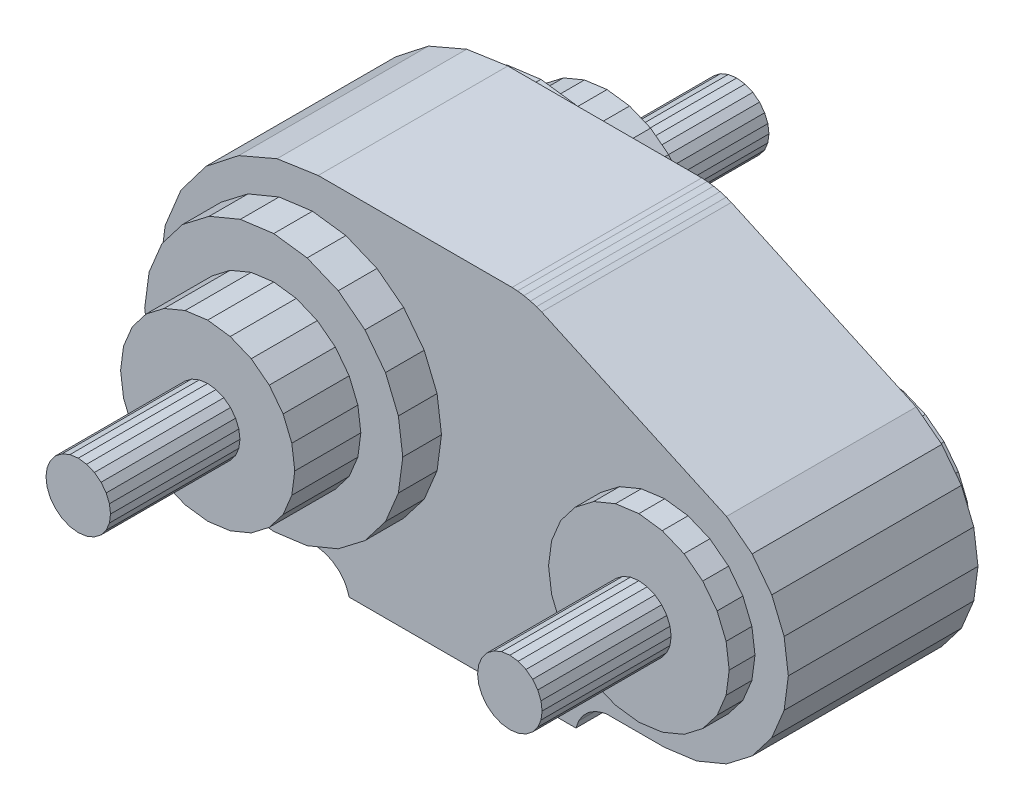
from build123d import *

# Parameters (mm, degrees)
BOSS_EXTRUDE1_DEPTH  = 14.699999809
BOSS_EXTRUDE2_DEPTH  = 2.000000954
BOSS_EXTRUDE3_DEPTH  = 10
BOSS_EXTRUDE4_DEPTH  = 3.000000954
BOSS_EXTRUDE5_DEPTH  = 5.119998932
BOSS_EXTRUDE6_DEPTH  = 10.029998779
BOSS_EXTRUDE7_DEPTH  = 2
BOSS_EXTRUDE8_DEPTH  = 3
BOSS_EXTRUDE9_DEPTH  = 5.130000114
BOSS_EXTRUDE10_DEPTH = 10.050000191
CUT_EXTRUDE1_DEPTH   = 6
CUT_EXTRUDE2_DEPTH   = 6
DRAFT1_ANGLE         = 19.74294867
CHAMFER1_SIZE2       = 0.158303092
CHAMFER1_SIZE        = 0.157016973
CHAMFER2_SIZE2       = 0.157642231
CHAMFER2_SIZE        = 0.157642267


with BuildPart() as part:
    # Sketch1 → Boss-Extrude1 (new body)
    with BuildSketch(Plane.XY.offset(14.699999809)):
        Polygon((26.931087494, 2.467746735), (29.242494583, 3.427928209), (31.226976395, 4.953178406), (32.749523163, 6.939733505), (33.706558228, 9.252446175), (34.032974243, 11.733979225), (33.706558228, 14.215512276), (32.749523163, 16.528224945), (31.226976395, 18.514780045), (29.242494583, 20.040029526), (14.914542198, 26.600000381), (14.518286705, 26.754508972), (14.043248177, 26.893892288), (13.535926819, 27.004508972), (13.045982361, 27.075529099), (12.62137413, 27.100000381), (-2.402890205, 27.100000381), (-5.592948914, 26.629587173), (-8.556154251, 25.357906342), (-11.094871521, 23.369771957), (-13.039776802, 20.797786713), (-14.26115036, 17.813493729), (-14.677532196, 14.615934372), (-14.26115036, 11.418374062), (-13.039776802, 8.434081078), (-11.094871521, 5.862095833), (-8.556154251, 3.873961449), (-5.592948914, 2.602279902), (-2.402890205, 2.131867886), (-1.797713399, 1.993236542), (-1.238033295, 1.724506974), (-0.751430988, 1.338922024), (0, 0.406370154), (0, 0), (17.573465347, 0), (17.573465347, 0.255007923), (18.116666794, 1.108045936), (18.5574646, 1.545258999), (19.08385849, 1.874450445), (19.819337772, 2.131654199), (24.450000763, 2.137956142), align=None)
    extrude(amount=-BOSS_EXTRUDE1_DEPTH)

    # Sketch2 → Boss-Extrude2 (add)
    with BuildSketch(Plane.XY.offset(14.699999809)):
        Polygon((17.450000763, 11.829999924), (17.688518524, 13.64173317), (18.387823105, 15.329999924), (19.50025177, 16.779747009), (20.950000763, 17.892177582), (22.638267517, 18.591480255), (24.450000763, 18.829999924), (26.261734009, 18.591480255), (27.950000763, 17.892177582), (29.399747849, 16.779747009), (30.512178421, 15.329999924), (31.211481094, 13.64173317), (31.450000763, 11.829999924), (31.211481094, 10.018266678), (30.512178421, 8.329999924), (29.399747849, 6.880252361), (27.950000763, 5.767822266), (26.261734009, 5.068519115), (24.450000763, 4.829999924), (22.638267517, 5.068519115), (20.950000763, 5.767822266), (19.50025177, 6.880252361), (18.387823105, 8.329999924), (17.688518524, 10.018266678), align=None)
    extrude(amount=BOSS_EXTRUDE2_DEPTH)

    # Sketch3 → Boss-Extrude3 (add)
    with BuildSketch(Plane.XY.offset(16.700000763)):
        Polygon((21.950000763, 11.829999924), (22.03518486, 12.47704792), (22.284936905, 13.079999924), (22.68223381, 13.597766876), (23.200000763, 13.995063782), (23.802951813, 14.244814873), (24.450000763, 14.329999924), (25.097047806, 14.244814873), (25.700000763, 13.995063782), (26.217767715, 13.597766876), (26.615062714, 13.079999924), (26.864814758, 12.47704792), (26.950000763, 11.829999924), (26.864814758, 11.182951927), (26.615062714, 10.579999924), (26.217767715, 10.062232971), (25.700000763, 9.664936066), (25.097047806, 9.415184975), (24.450000763, 9.329999924), (23.802951813, 9.415184975), (23.200000763, 9.664936066), (22.68223381, 10.062232971), (22.284936905, 10.579999924), (22.03518486, 11.182951927), align=None)
    extrude(amount=BOSS_EXTRUDE3_DEPTH)

    # Sketch4 → Boss-Extrude4 (add)
    with BuildSketch(Plane.XY.offset(14.699999809)):
        Polygon((-0.259341866, 4.820741653), (-2.847532272, 4.480000019), (-5.435722828, 4.820741653), (-7.847532272, 5.819746017), (-9.918600082, 7.408932209), (-11.507786751, 9.479999542), (-12.506790161, 11.891809464), (-12.847532272, 14.479999542), (-12.506790161, 17.068189621), (-11.507786751, 19.479999542), (-9.918600082, 21.551067352), (-7.847532272, 23.140254974), (-5.435722828, 24.139257431), (-2.847532272, 24.479999542), (-0.259341866, 24.139257431), (2.152467728, 23.140254974), (4.223535538, 21.551067352), (5.812721729, 19.479999542), (6.811726093, 17.068189621), (7.152467728, 14.479999542), (6.811726093, 11.891809464), (5.812721729, 9.479999542), (4.223535538, 7.408932209), (2.152467728, 5.819746017), align=None)
    extrude(amount=BOSS_EXTRUDE4_DEPTH)

    # Sketch5 → Boss-Extrude5 (add)
    with BuildSketch(Plane.XY.offset(17.700000763)):
        Polygon((-1.100503802, 7.960000515), (-2.847532272, 7.730000019), (-4.594560623, 7.960000515), (-6.222532272, 8.634328842), (-7.620502949, 9.707029343), (-8.693203926, 11.104999542), (-9.367531776, 12.732971191), (-9.597532272, 14.479999542), (-9.367531776, 16.227027893), (-8.693203926, 17.854999542), (-7.620502949, 19.252971649), (-6.222532272, 20.32567215), (-4.594560623, 21), (-2.847532272, 21.229999542), (-1.100503802, 21), (0.527467668, 20.32567215), (1.925438523, 19.252971649), (2.998139143, 17.854999542), (3.672466993, 16.227027893), (3.902467728, 14.479999542), (3.672466993, 12.732971191), (2.998139143, 11.104999542), (1.925438523, 9.707029343), (0.527467668, 8.634328842), align=None)
    extrude(amount=BOSS_EXTRUDE5_DEPTH)

    # Sketch6 → Boss-Extrude6 (add)
    with BuildSketch(Plane.XY.offset(22.819999695)):
        Polygon((-1.597532272, 12.314936638), (-2.200484753, 12.065185547), (-2.847532272, 11.979999542), (-3.49458003, 12.065185547), (-4.097532272, 12.314936638), (-4.615299225, 12.71223259), (-5.012595654, 13.229999542), (-5.262346745, 13.832952499), (-5.347532272, 14.479999542), (-5.262346745, 15.127047539), (-5.012595654, 15.729999542), (-4.615299225, 16.247766495), (-4.097532272, 16.6450634), (-3.49458003, 16.894815445), (-2.847532272, 16.979999542), (-2.200484753, 16.894815445), (-1.597532272, 16.6450634), (-1.07976532, 16.247766495), (-0.682468772, 15.729999542), (-0.432717741, 15.127047539), (-0.347532302, 14.479999542), (-0.432717741, 13.832952499), (-0.682468772, 13.229999542), (-1.07976532, 12.71223259), align=None)
    extrude(amount=BOSS_EXTRUDE6_DEPTH)

    # Sketch7 → Boss-Extrude7 (add)
    with BuildSketch(Plane(origin=(0, 0, 0), x_dir=(-1, 0, 0), z_dir=(0, 0, -1))):
        Polygon((-27.950000763, 5.767822266), (-29.399747849, 6.880252361), (-30.512178421, 8.329999924), (-31.211481094, 10.018266678), (-31.450000763, 11.829999924), (-31.211481094, 13.64173317), (-30.512178421, 15.329999924), (-29.399747849, 16.779747009), (-27.950000763, 17.892177582), (-26.261734009, 18.591480255), (-24.450000763, 18.829999924), (-22.638267517, 18.591480255), (-20.950000763, 17.892177582), (-19.50025177, 16.779747009), (-18.387823105, 15.329999924), (-17.688518524, 13.64173317), (-17.450000763, 11.829999924), (-17.688518524, 10.018266678), (-18.387823105, 8.329999924), (-19.50025177, 6.880252361), (-20.950000763, 5.767822266), (-22.638267517, 5.068519115), (-24.450000763, 4.829999924), (-26.261734009, 5.068519115), align=None)
    extrude(amount=BOSS_EXTRUDE7_DEPTH)

    # Sketch8 → Boss-Extrude8 (add)
    with BuildSketch(Plane(origin=(0, 0, 0), x_dir=(-1, 0, 0), z_dir=(0, 0, -1))):
        Polygon((9.918600082, 21.551067352), (11.507786751, 19.479999542), (12.506790161, 17.068189621), (12.847532272, 14.479999542), (12.506790161, 11.891809464), (11.507786751, 9.479999542), (9.918600082, 7.408932209), (7.847532272, 5.819746017), (5.435722828, 4.820741653), (2.847532272, 4.480000019), (0.259341866, 4.820741653), (-2.152467728, 5.819746017), (-4.223535538, 7.408932209), (-5.812721729, 9.479999542), (-6.811726093, 11.891809464), (-7.152467728, 14.479999542), (-6.811726093, 17.068189621), (-5.812721729, 19.479999542), (-4.223535538, 21.551067352), (-2.152467728, 23.140254974), (0.259341866, 24.139257431), (2.847532272, 24.479999542), (5.435722828, 24.139257431), (7.847532272, 23.140254974), align=None)
    extrude(amount=BOSS_EXTRUDE8_DEPTH)

    # Sketch9 → Boss-Extrude9 (add)
    with BuildSketch(Plane(origin=(0, 0, -3), x_dir=(-1, 0, 0), z_dir=(0, 0, -1))):
        Polygon((4.594560623, 21), (6.222532272, 20.32567215), (7.620502949, 19.252971649), (8.693203926, 17.854999542), (9.367531776, 16.227027893), (9.597532272, 14.479999542), (9.367531776, 12.732971191), (8.693203926, 11.104999542), (7.620502949, 9.707029343), (6.222532272, 8.634328842), (4.594560623, 7.960000515), (2.847532272, 7.730000019), (1.100503802, 7.960000515), (-0.527467668, 8.634328842), (-1.925438523, 9.707029343), (-2.998139143, 11.104999542), (-3.672466993, 12.732971191), (-3.902467728, 14.479999542), (-3.672466993, 16.227027893), (-2.998139143, 17.854999542), (-1.925438523, 19.252971649), (-0.527467668, 20.32567215), (1.100503802, 21), (2.847532272, 21.229999542), align=None)
    extrude(amount=BOSS_EXTRUDE9_DEPTH)

    # Sketch10 → Boss-Extrude10 (add)
    with BuildSketch(Plane(origin=(0, 0, -8.130000114), x_dir=(-1, 0, 0), z_dir=(0, 0, -1))):
        Polygon((0.432717741, 13.832952499), (0.347532302, 14.479999542), (0.432717741, 15.127047539), (0.682468772, 15.729999542), (1.07976532, 16.247766495), (1.597532272, 16.6450634), (2.200484753, 16.894815445), (2.847532272, 16.979999542), (3.49458003, 16.894815445), (4.097532272, 16.6450634), (4.615299225, 16.247766495), (5.012595654, 15.729999542), (5.262346745, 15.127047539), (5.347532272, 14.479999542), (5.262346745, 13.832952499), (5.012595654, 13.229999542), (4.615299225, 12.71223259), (4.097532272, 12.314936638), (3.49458003, 12.065185547), (2.847532272, 11.979999542), (2.200484753, 12.065185547), (1.597532272, 12.314936638), (1.07976532, 12.71223259), (0.682468772, 13.229999542), align=None)
    extrude(amount=BOSS_EXTRUDE10_DEPTH)

    # Sketch11 → Cut-Extrude1 (cut)
    with BuildSketch(Plane.XZ):
        Polygon((13.478983879, 2.843444586), (13.808978081, 2.799999952), (14.138972282, 2.843444586), (14.44647789, 2.970817566), (14.710538864, 3.173438787), (14.913160324, 3.4375), (15.040533066, 3.745005608), (15.083977699, 4.074999809), (15.040533066, 4.404994488), (14.913160324, 4.712500095), (14.710538864, 4.976561069), (14.44647789, 5.179182529), (14.138972282, 5.306555271), (13.808978081, 5.349999905), (13.478983879, 5.306555271), (13.171478271, 5.179182529), (12.907416344, 4.976561069), (12.704795837, 4.712500095), (12.577422142, 4.404994488), (12.533977509, 4.074999809), (12.577422142, 3.745005608), (12.704795837, 3.4375), (12.907416344, 3.173438787), (13.171478271, 2.970817566), align=None)
    extrude(amount=-CUT_EXTRUDE1_DEPTH, mode=Mode.SUBTRACT)

    # Sketch12 → Cut-Extrude2 (cut)
    with BuildSketch(Plane.XZ):
        Polygon((2.57742238, 3.745005608), (2.704795599, 3.4375), (2.907416821, 3.173438787), (3.171477795, 2.970817566), (3.478983641, 2.843444586), (3.808977842, 2.799999952), (4.138972282, 2.843444586), (4.44647789, 2.970817566), (4.710538864, 3.173438787), (4.913160324, 3.4375), (5.040533543, 3.745005608), (5.083977699, 4.074999809), (5.040533543, 4.404994488), (4.913160324, 4.712500095), (4.710538864, 4.976561069), (4.44647789, 5.179182529), (4.138972282, 5.306555271), (3.808977842, 5.349999905), (3.478983641, 5.306555271), (3.171477795, 5.179182529), (2.907416821, 4.976561069), (2.704795599, 4.712500095), (2.57742238, 4.404994488), (2.533977985, 4.074999809), align=None)
    extrude(amount=-CUT_EXTRUDE2_DEPTH, mode=Mode.SUBTRACT)

    # Draft1
    draft1_faces = [part.faces().sort_by_distance(p)[0] for p in [
        (0, 0.203185077, 7.349999905),
        (17.573465347, 0.127503961, 7.349999905),
    ]]
    draft(draft1_faces, Plane(origin=(0, 0, 0), x_dir=(-1, 0, 0), z_dir=(0, -1, 0)), DRAFT1_ANGLE)

    # Chamfer1
    chamfer1_edges = [part.edges().sort_by_distance(p)[0] for p in [
        (19.819337772, 2.131654199, 7.349999905),
    ]]
    chamfer(chamfer1_edges, length=CHAMFER1_SIZE, length2=CHAMFER1_SIZE2)

    # Chamfer2
    chamfer2_edges = [part.edges().sort_by_distance(p)[0] for p in [
        (-0.262976078, 0.73273257, 7.349999905),
    ]]
    chamfer(chamfer2_edges, length=CHAMFER2_SIZE, length2=CHAMFER2_SIZE2)


solid = part.part
